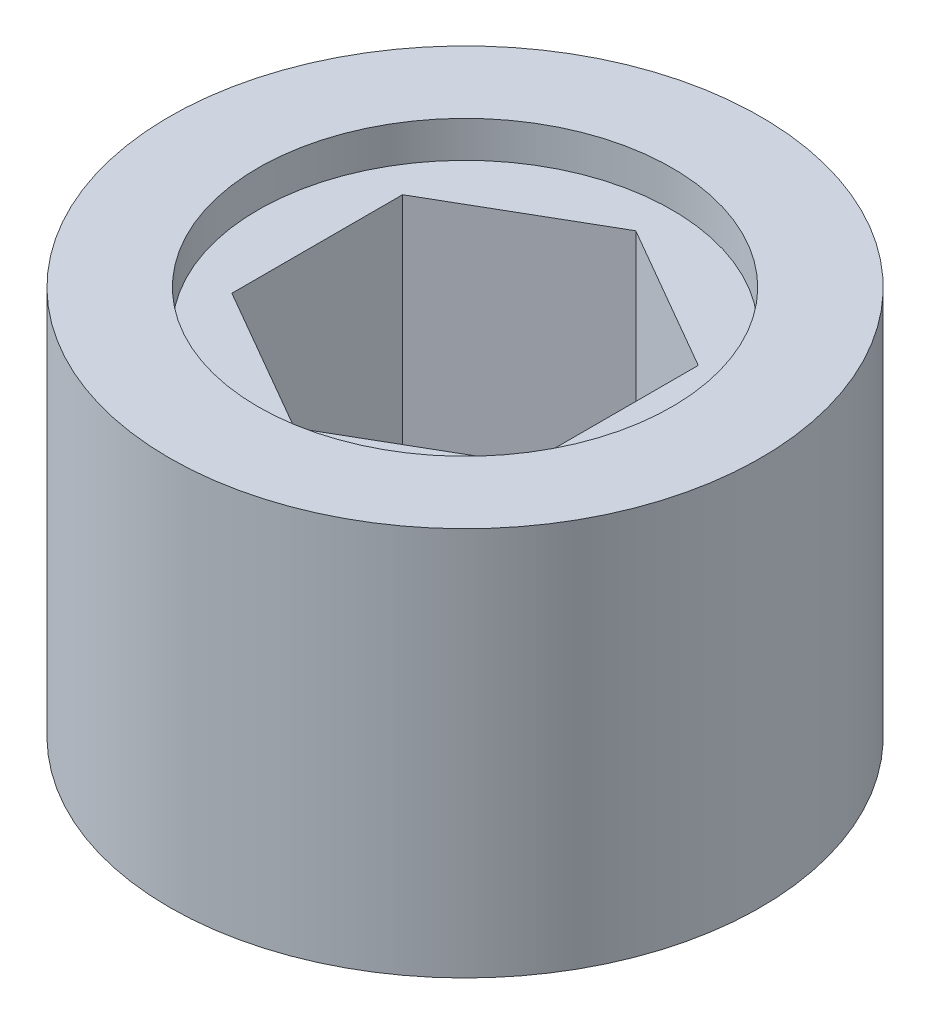
from build123d import *

# Parameters (mm, degrees)
SKETCH1_R           = 12.7
SKETCH1_R_2         = 8.89
BOSS_EXTRUDE1_DEPTH = 16.7132
SKETCH1_3_R         = 8.89
BOSS_EXTRUDE2_DEPTH = 15.1511


with BuildPart() as part:
    # Sketch1 → Boss-Extrude1 (new body)
    with BuildSketch(Plane(origin=(0, 0, 0), x_dir=(1, 0, 0), z_dir=(0, 1, 0))):
        Circle(SKETCH1_R)
        Circle(SKETCH1_R_2, mode=Mode.SUBTRACT)
    extrude(amount=BOSS_EXTRUDE1_DEPTH)

    # Sketch1_3 → Boss-Extrude2 (add)
    with BuildSketch(Plane(origin=(0, 0, 0), x_dir=(1, 0, 0), z_dir=(0, 1, 0))):
        Circle(SKETCH1_3_R)
        Polygon((0, 7.332348419), (6.35, 3.666174209), (6.35, -3.666174209), (0, -7.332348419), (-6.35, -3.666174209), (-6.35, 3.666174209), align=None, mode=Mode.SUBTRACT)
    extrude(amount=BOSS_EXTRUDE2_DEPTH)


solid = part.part
